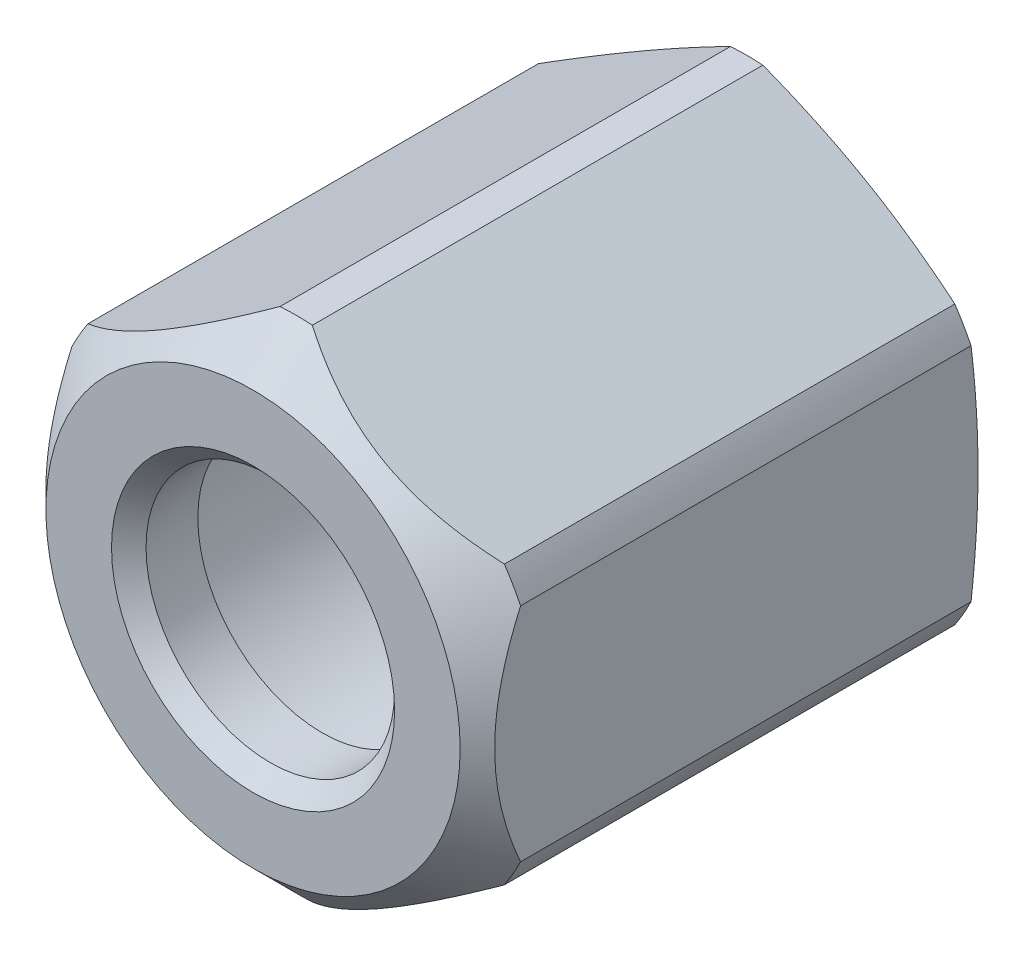
from build123d import *

# Parameters (mm, degrees)
SCHNITT_LINEAR_AUSTRAGEN1_DEPTH      = 30
SCHNITT_LINEAR_AUSTRAGEN1_DEPTH_BACK = 30
SKIZZE2_W                            = 67.3333
SKIZZE2_H                            = 68


with BuildPart() as part:
    # Skizze1 → Rotation1 (revolve)
    with BuildSketch(Plane(origin=(0, 0, 0), x_dir=(0, 0, -1), z_dir=(1, 0, 0))):
        Polygon((0, 4.1), (0.5, 3.6), (2, 3.6), (2, 4.9), (10.8, 4.9), (10.8, 4.4585), (13.9585, 4.4585), (14.5, 5), (14.5, 6.5), (14.299038106, 7.25), (1.25, 7.25), (0, 6), align=None)
    revolve(axis=Axis((0, 0, -14.5), (0, 0, 1)))

    # Skizze2 → Schnitt-Linear austragen1 (cut, two sides: drawn at the far end of the back side and taken through both)
    with BuildSketch(Plane.XY.offset(-SCHNITT_LINEAR_AUSTRAGEN1_DEPTH_BACK)):
        with Locations((-1.08335, 0.1667)):
            Rectangle(SKIZZE2_W, SKIZZE2_H)
        Polygon((-6.5, -3.75277675), (0, -7.505553499), (6.5, -3.75277675), (6.5, 3.75277675), (0, 7.505553499), (-6.5, 3.75277675), align=None, mode=Mode.SUBTRACT)
    extrude(amount=SCHNITT_LINEAR_AUSTRAGEN1_DEPTH + SCHNITT_LINEAR_AUSTRAGEN1_DEPTH_BACK, mode=Mode.SUBTRACT)


solid = part.part
